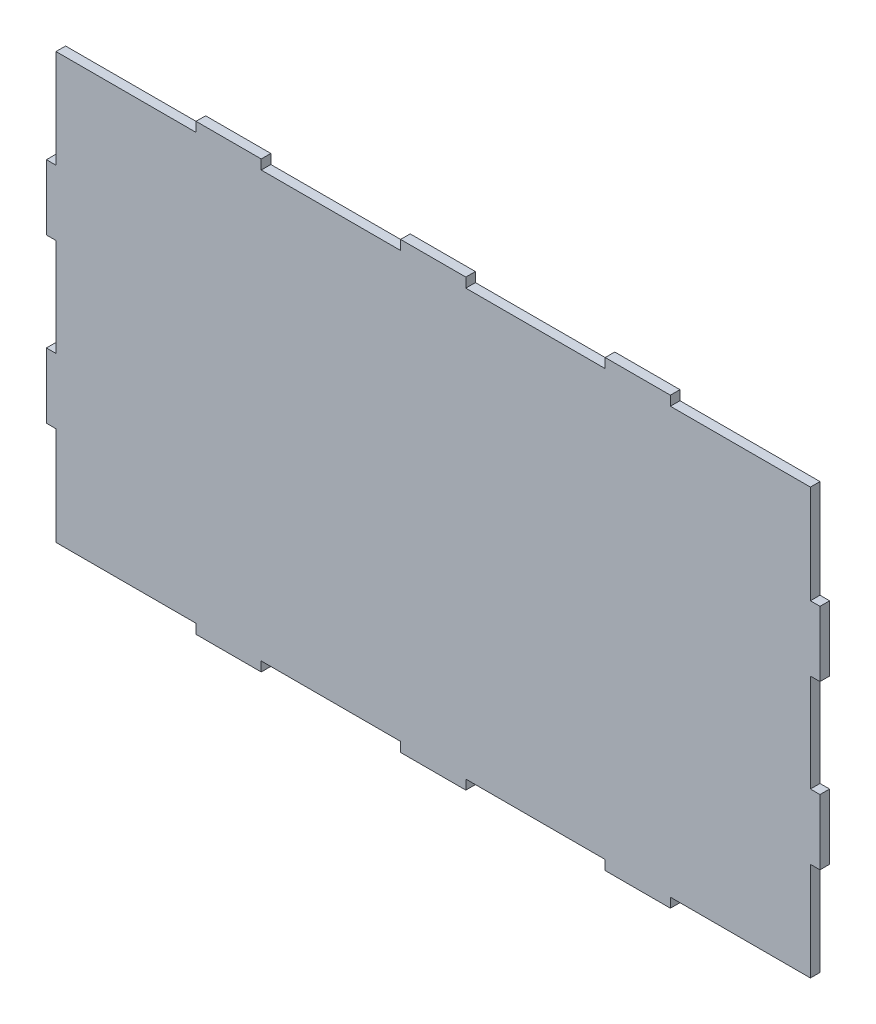
from build123d import *

# Parameters (mm, degrees)
EXTRUDE_3_DEPTH = 3


with BuildPart() as part:
    # Эскиз4 → Бобышка-Вытянуть3 (new body)
    with BuildSketch(Plane.XY):
        Polygon((43.8, 133), (0, 133), (0, 102.2), (-3, 102.2), (-3, 81.8), (0, 81.8), (0, 60.66), (0, 51.2), (-3, 51.2), (-3, 30.8), (0, 30.8), (0, 0), (43.8, 0), (43.8, -3), (64.2, -3), (64.2, 0), (107.8, 0), (107.8, -3), (128.2, -3), (128.2, 0), (171.8, 0), (171.8, -3), (192.2, -3), (192.2, 0), (236, 0), (236, 30.8), (239, 30.8), (239, 51.2), (236, 51.2), (236, 81.8), (239, 81.8), (239, 102.2), (236, 102.2), (236, 133), (192.2, 133), (192.2, 136), (171.8, 136), (171.8, 133), (128.2, 133), (128.2, 136), (107.8, 136), (107.8, 133), (64.2, 133), (64.2, 136), (43.8, 136), align=None)
    extrude(amount=EXTRUDE_3_DEPTH)


solid = part.part
